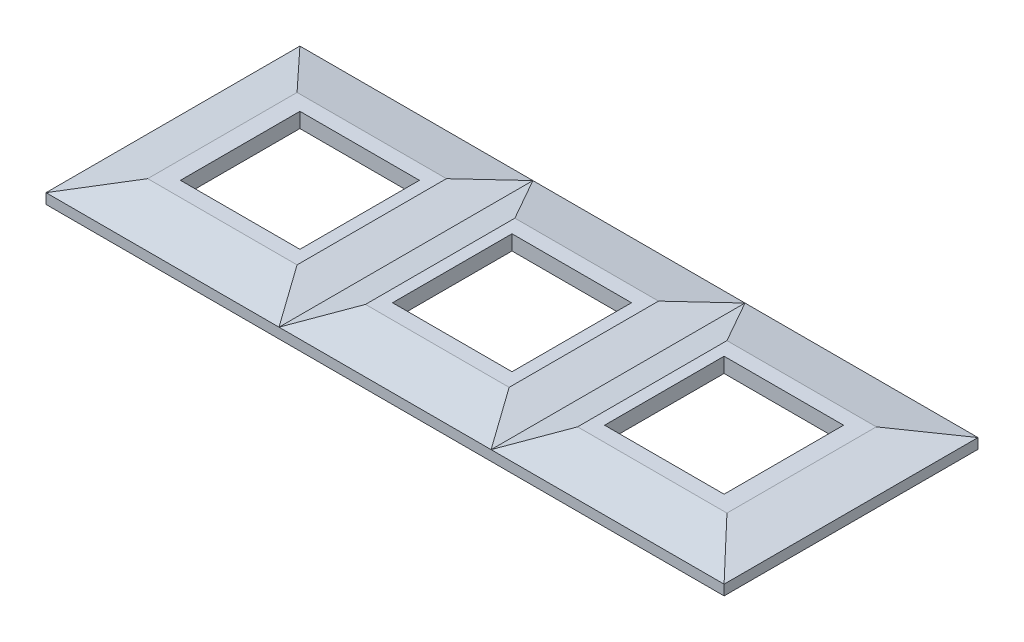
from build123d import *

# Parameters (mm, degrees)
EXTRUDE_1_DEPTH     = 42.5
SKETCH_2_OUTSIDE_W  = 135.498
SKETCH_2_OUTSIDE_H  = 57.498
CUT_EXTRUDE_1_DEPTH = 123
SKETCH_3_W          = 40
SKETCH_3_H          = 40
CUT_EXTRUDE_2_DEPTH = 8
SKETCH_4_W          = 223
SKETCH_4_H          = 82
CUT_EXTRUDE_3_DEPTH = 1
SKETCH_5_W          = 213
SKETCH_5_H          = 71
CUT_EXTRUDE_4_DEPTH = 1


with BuildPart() as part:
    # Эскиз1 → Бобышка-Вытянуть1 (new body, symmetric)
    with BuildSketch(Plane.XY):
        Polygon((-113.5, 0), (-113.5, 3.420983787), (-96.95384839, 7), (-46.95384839, 7), (-35.5, 3.420983787), (-24.04615161, 7), (24.04615161, 7), (35.5, 3.420983787), (46.95384839, 7), (96.95384839, 7), (113.5, 3.420983787), (113.5, 0), align=None)
    extrude(amount=EXTRUDE_1_DEPTH, both=True)

    # Эскиз2 outside → Вырез-Вытянуть1 (cut, symmetric)
    with BuildSketch(Plane(origin=(0, 0, 0), x_dir=(0, 0, -1), z_dir=(1, 0, 0))):
        with Locations((0, 3.5)):
            Rectangle(SKETCH_2_OUTSIDE_W, SKETCH_2_OUTSIDE_H)
        Polygon((42.5, 0), (-42.5, 0), (-42.5, 3.420983787), (-25, 7), (25, 7), (42.5, 3.420983787), align=None, mode=Mode.SUBTRACT)
    extrude(amount=CUT_EXTRUDE_1_DEPTH, both=True, mode=Mode.SUBTRACT)

    # Эскиз3 → Вырез-Вытянуть2 (cut, through all)
    with BuildSketch(Plane.XZ):
        with Locations((71, 0)):
            Rectangle(SKETCH_3_W, SKETCH_3_H)
        Rectangle(SKETCH_3_W, SKETCH_3_H)
        with Locations((-71, 0)):
            Rectangle(SKETCH_3_W, SKETCH_3_H)
    extrude(amount=-CUT_EXTRUDE_2_DEPTH, mode=Mode.SUBTRACT)

    # Эскиз4 → Вырез-Вытянуть3 (cut)
    with BuildSketch(Plane.XZ):
        Rectangle(SKETCH_4_W, SKETCH_4_H)
    extrude(amount=-CUT_EXTRUDE_3_DEPTH, mode=Mode.SUBTRACT)

    # Эскиз5 → Вырез-Вытянуть4 (cut)
    with BuildSketch(Plane.XZ.offset(-1)):
        Rectangle(SKETCH_5_W, SKETCH_5_H)
    extrude(amount=-CUT_EXTRUDE_4_DEPTH, mode=Mode.SUBTRACT)


solid = part.part
